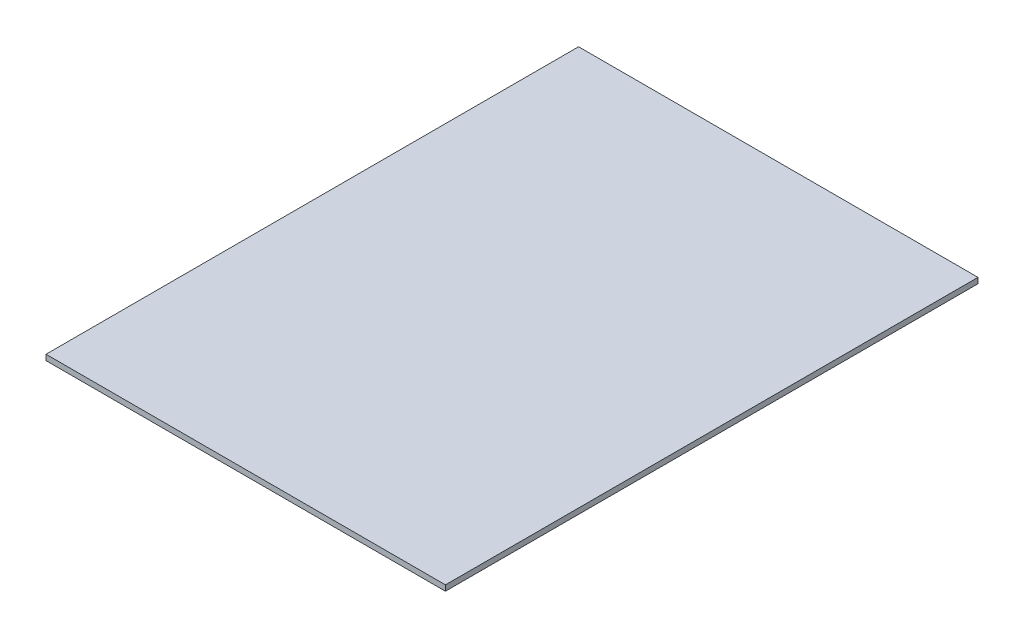
from build123d import *

# Parameters (mm, degrees)
SKETCH1_W           = 457.2
SKETCH1_H           = 609.6
BOSS_EXTRUDE1_DEPTH = 6.35


with BuildPart() as part:
    # Sketch1 → Boss-Extrude1 (new body)
    with BuildSketch(Plane(origin=(0, 0, 0), x_dir=(1, 0, 0), z_dir=(0, 1, 0))):
        with Locations((0.192419695, -488.214923849)):
            Rectangle(SKETCH1_W, SKETCH1_H)
    extrude(amount=-BOSS_EXTRUDE1_DEPTH)


solid = part.part
